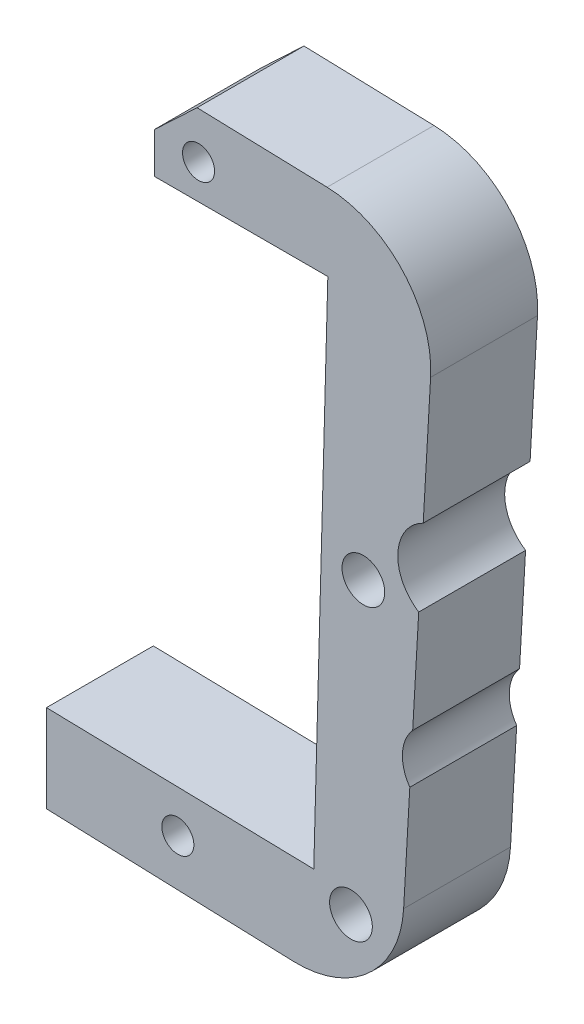
from build123d import *

# Parameters (mm, degrees)
SKETCH1_R           = 1
BOSS_EXTRUDE1_DEPTH = 5
SKETCH2_R           = 0.75
CUT_EXTRUDE1_DEPTH  = 5
CHAMFER1_SIZE2      = 2
CHAMFER1_SIZE       = 1.943358552


with BuildPart() as part:
    # Sketch1 → Boss-Extrude1 (new body)
    with BuildSketch(Plane.XY):
        with BuildLine():
            Line((63.978592029, 21.214561498), (63.978592029, 25.05586024))
            Line((63.978592029, 25.05586024), (72.058256518, 24.816727889))
            ThreePointArc((72.058256518, 24.816727889), (75.595399687, 23.198311963), (76.902246949, 19.534597706))
            Line((76.902246949, 19.534597706), (76.555916572, 13.453920838))
            ThreePointArc((76.555916572, 13.453920838), (75.36962468, 11.661641728), (76.3447433, 9.746257553))
            Line((76.3447433, 9.746257553), (76.063685342, 4.811597648))
            ThreePointArc((76.063685342, 4.811597648), (75.584983034, 3.649375801), (75.928626908, 2.440316493))
            Line((75.928626908, 2.440316493), (75.640205821, -2.623621136))
            ThreePointArc((75.640205821, -2.623621136), (74.017880394, -6.033338403), (70.473798594, -7.336256597))
            Line((70.473798594, -7.336256597), (58.930433709, -6.933153413))
            Line((58.930433709, -6.933153413), (58.930433709, -2.832883595))
            Line((58.930433709, -2.832883595), (71.435141734, -3.122466307))
            Line((71.435141734, -3.122466307), (72.093475791, 21.214561498))
            Line((72.093475791, 21.214561498), (63.978592029, 21.214561498))
        make_face()
        with Locations((73.176178498, -4.091448782)):
            Circle(SKETCH1_R, mode=Mode.SUBTRACT)
        with Locations((73.756130882, 9.746257553)):
            Circle(SKETCH1_R, mode=Mode.SUBTRACT)
    extrude(amount=BOSS_EXTRUDE1_DEPTH)

    # Sketch2 → Cut-Extrude1 (cut)
    with BuildSketch(Plane.XY.offset(5)):
        with Locations((65.076045823, -4.950719542)):
            Circle(SKETCH2_R)
        with Locations((66.046251832, 22.832345449)):
            Circle(SKETCH2_R)
    extrude(amount=-CUT_EXTRUDE1_DEPTH, mode=Mode.SUBTRACT)

    # Chamfer1
    chamfer1_edges = [part.edges().sort_by_distance(p)[0] for p in [
        (63.978592029, 25.05586024, 2.5),
    ]]
    chamfer(chamfer1_edges, length=CHAMFER1_SIZE, length2=CHAMFER1_SIZE2)


solid = part.part
